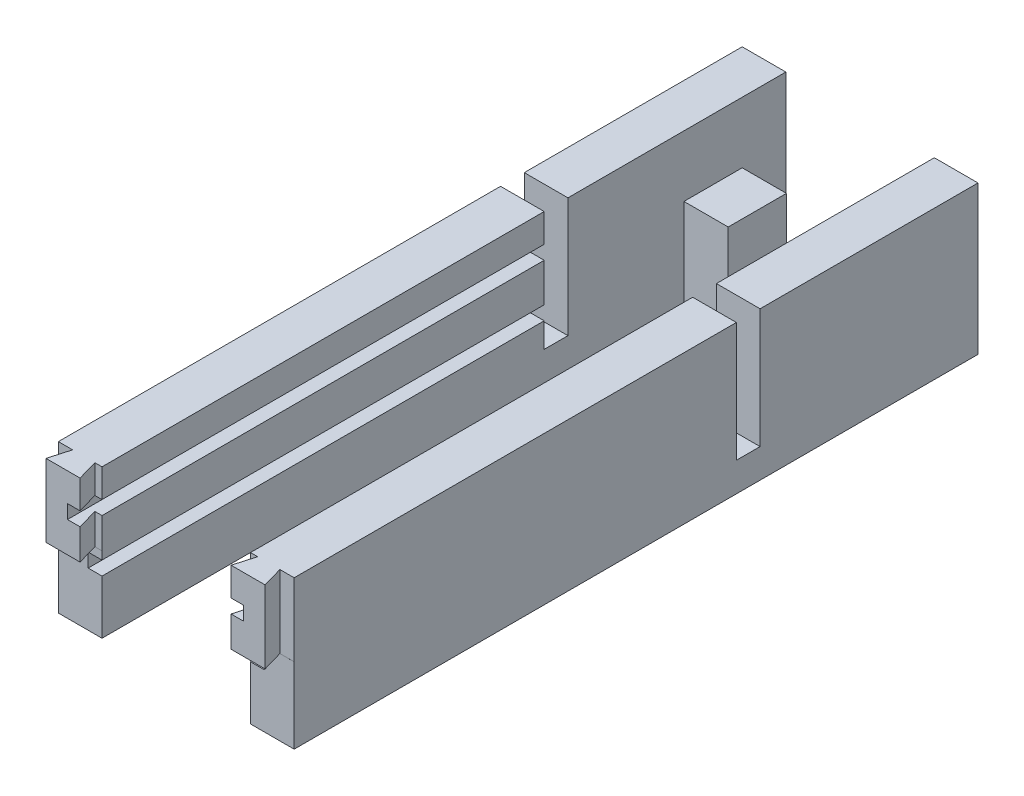
from build123d import *

# Parameters (mm, degrees)
SKETCH1_W           = 242
SKETCH1_H           = 51
BOSS_EXTRUDE1_DEPTH = 15
CUT_EXTRUDE8_DEPTH  = 25
SKETCH13_W          = 15
SKETCH13_H          = 7.11
CUT_EXTRUDE9_DEPTH  = 26
SKETCH17_W          = 15
SKETCH17_H          = 8.15
CUT_EXTRUDE10_DEPTH = 41
SKETCH7_W           = 4.75
SKETCH7_H           = 4.75
CUT_EXTRUDE5_DEPTH  = 165
SKETCH25_W          = 12.5
SKETCH25_H          = 10
BOSS_EXTRUDE3_DEPTH = 30
SKETCH26_W          = 20
SKETCH26_H          = 30
BOSS_EXTRUDE4_DEPTH = 15.2


with BuildPart() as part:
    # Sketch1 → Boss-Extrude1 (new body)
    with BuildSketch(Plane(origin=(0, 0, 0), x_dir=(0, 0, -1), z_dir=(1, 0, 0))):
        with Locations((56.437921078, 5.057266603)):
            Rectangle(SKETCH1_W, SKETCH1_H)
    extrude(amount=BOSS_EXTRUDE1_DEPTH)

    # Sketch12 → Cut-Extrude8 (cut)
    with BuildSketch(Plane(origin=(0, 30.557266603, 0), x_dir=(1, 0, 0), z_dir=(0, 1, 0))):
        Polygon((0, -57.448742372), (4.909716433, -57.448742372), (2.87, -64.562078922), (0, -64.562078922), align=None)
        Polygon((15, -57.448742372), (15, -64.562078922), (14.57, -64.562078922), (12.530283567, -57.448742372), align=None)
    extrude(amount=-CUT_EXTRUDE8_DEPTH, mode=Mode.SUBTRACT)

    # Sketch13 → Cut-Extrude9 (cut)
    with BuildSketch(Plane.XZ.offset(20.442733397)):
        with Locations((7.5, 61.007078922)):
            Rectangle(SKETCH13_W, SKETCH13_H)
    extrude(amount=-CUT_EXTRUDE9_DEPTH, mode=Mode.SUBTRACT)

    # Sketch17 → Cut-Extrude10 (cut)
    with BuildSketch(Plane(origin=(0, 30.557266603, 0), x_dir=(1, 0, 0), z_dir=(0, 1, 0))):
        with Locations((7.5, 98.512921078)):
            Rectangle(SKETCH17_W, SKETCH17_H)
    extrude(amount=-CUT_EXTRUDE10_DEPTH, mode=Mode.SUBTRACT)

    # Sketch7 → Cut-Extrude5 (cut)
    with BuildSketch(Plane(origin=(0, 0, -94.437921078), x_dir=(-1, 0, 0), z_dir=(0, 0, -1))):
        with Locations((-12.625, 0.432266603)):
            Rectangle(SKETCH7_W, SKETCH7_H)
        with Locations((-12.625, 18.432266603)):
            Rectangle(SKETCH7_W, SKETCH7_H)
    extrude(amount=-CUT_EXTRUDE5_DEPTH, mode=Mode.SUBTRACT)


with BuildPart() as body_2:
    # Mirror4: mirrored copy
    add(part.part.mirror(Plane(origin=(40.5, 0, 0), x_dir=(0, 0, 1), z_dir=(1, 0, 0))))


with BuildPart() as part_1:
    add(part.part)

    # Sketch25 → Boss-Extrude3 (add)
    with BuildSketch(Plane(origin=(15, 0, 0), x_dir=(0, 0, -1), z_dir=(1, 0, 0))):
        with Locations((153.687921078, -15.442733397)):
            Rectangle(SKETCH25_W, SKETCH25_H)
    extrude(amount=BOSS_EXTRUDE3_DEPTH)

    # Sketch26 → Boss-Extrude4 (add)
    with BuildSketch(Plane(origin=(15, 0, 0), x_dir=(0, 0, -1), z_dir=(1, 0, 0))):
        with Locations((152.437921078, -5.442733397)):
            Rectangle(SKETCH26_W, SKETCH26_H)
    extrude(amount=BOSS_EXTRUDE4_DEPTH)


solid = Compound([body_2.part, part_1.part])
